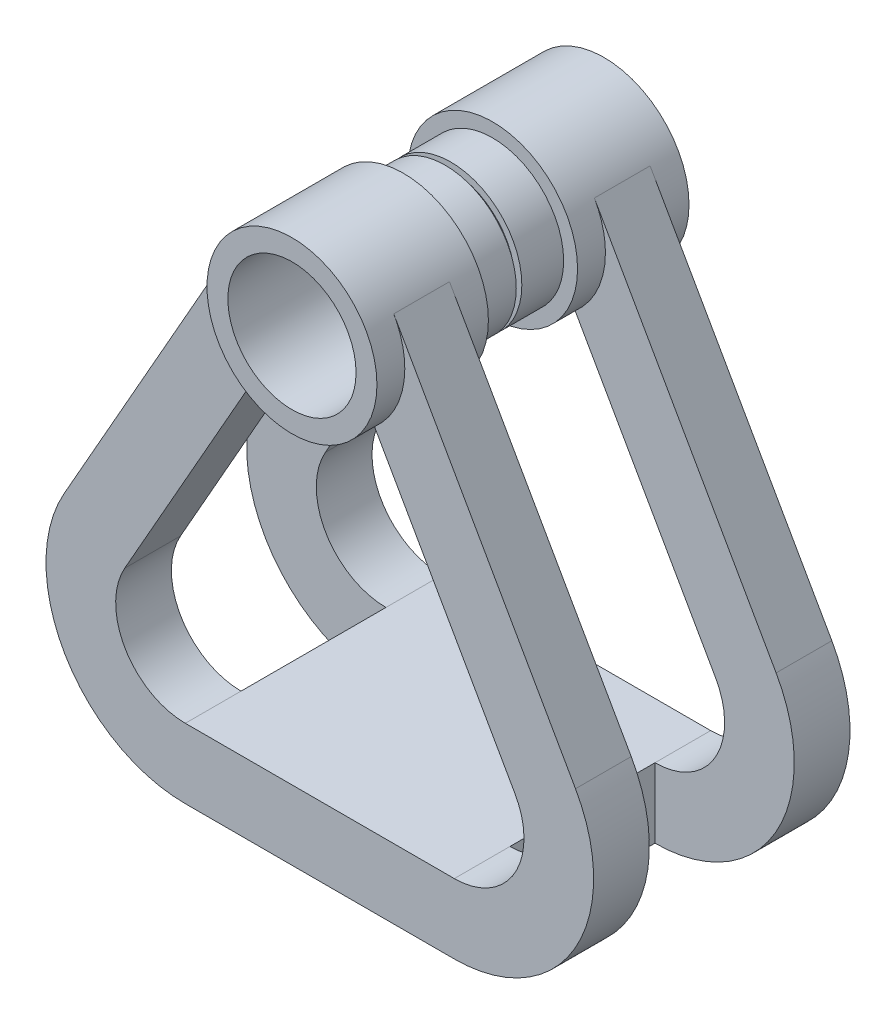
from build123d import *

# Parameters (mm, degrees)
SKETCH1_R                = 5.1
SKETCH1_R_2              = 4.6
EXTRUDE_THIN1_DEPTH      = 11
SKETCH2_R                = 6.1
SKETCH2_R_2              = 5.1
BOSS_EXTRUDE2_DEPTH      = 8
BOSS_EXTRUDE3_DEPTH      = 2
BOSS_EXTRUDE3_DEPTH_BACK = 2
SKETCH4_W                = 19.308386588
SKETCH4_H                = 5
BOSS_EXTRUDE4_DEPTH      = 5.2


with BuildPart() as part:
    # Sketch1 → Extrude-Thin1 (new body)
    with BuildSketch(Plane.XY):
        Circle(SKETCH1_R)
        Circle(SKETCH1_R_2, mode=Mode.SUBTRACT)
    extrude(amount=EXTRUDE_THIN1_DEPTH)

    # Sketch2 → Boss-Extrude2 (add)
    with BuildSketch(Plane.XY.offset(11)):
        Circle(SKETCH2_R)
        Circle(SKETCH2_R_2, mode=Mode.SUBTRACT)
    extrude(amount=-BOSS_EXTRUDE2_DEPTH)

    # Sketch3 → Boss-Extrude3 (add, two sides)
    with BuildSketch(Plane.XY.offset(7)) as boss_extrude3_sk:
        with BuildLine():
            Line((5.305614658, 3.010058653), (18.351922243, -19.9857327))
            ThreePointArc((18.351922243, -19.9857327), (18.2955249, -29.952887404), (9.654193294, -34.920255082))
            Line((9.654193294, -34.920255082), (-9.654193294, -34.920255082))
            ThreePointArc((-9.654193294, -34.920255082), (-18.2955249, -29.952887404), (-18.351922243, -19.9857327))
            Line((-18.351922243, -19.9857327), (-5.305614658, 3.010058653))
            ThreePointArc((-5.305614658, 3.010058653), (-6.002878674, -1.084180624), (-3.917463614, -4.675839907))
            Line((-3.917463614, -4.675839907), (-14.003057769, -22.452993891))
            ThreePointArc((-14.003057769, -22.452993891), (-13.974859097, -27.436571243), (-9.654193294, -29.920255082))
            Line((-9.654193294, -29.920255082), (9.654193294, -29.920255082))
            ThreePointArc((9.654193294, -29.920255082), (13.974859097, -27.436571243), (14.003057769, -22.452993891))
            Line((14.003057769, -22.452993891), (3.917463614, -4.675839907))
            ThreePointArc((3.917463614, -4.675839907), (6.002878674, -1.084180624), (5.305614658, 3.010058653))
        make_face()
    extrude(amount=BOSS_EXTRUDE3_DEPTH)
    extrude(boss_extrude3_sk.sketch, amount=-BOSS_EXTRUDE3_DEPTH_BACK)

    # Sketch4 → Boss-Extrude4 (add)
    with BuildSketch(Plane(origin=(0, 0, -0.2), x_dir=(-1, 0, 0), z_dir=(0, 0, -1))):
        with Locations((0, -32.420255082)):
            Rectangle(SKETCH4_W, SKETCH4_H)
    extrude(amount=-BOSS_EXTRUDE4_DEPTH)

    # Mirror3: part across plane


with BuildPart() as part_1:
    add(part.part)
    add(part.part.mirror(Plane(origin=(0, 0, -0.2), x_dir=(1, 0, 0), z_dir=(0, 0, -1))))


solid = part_1.part
